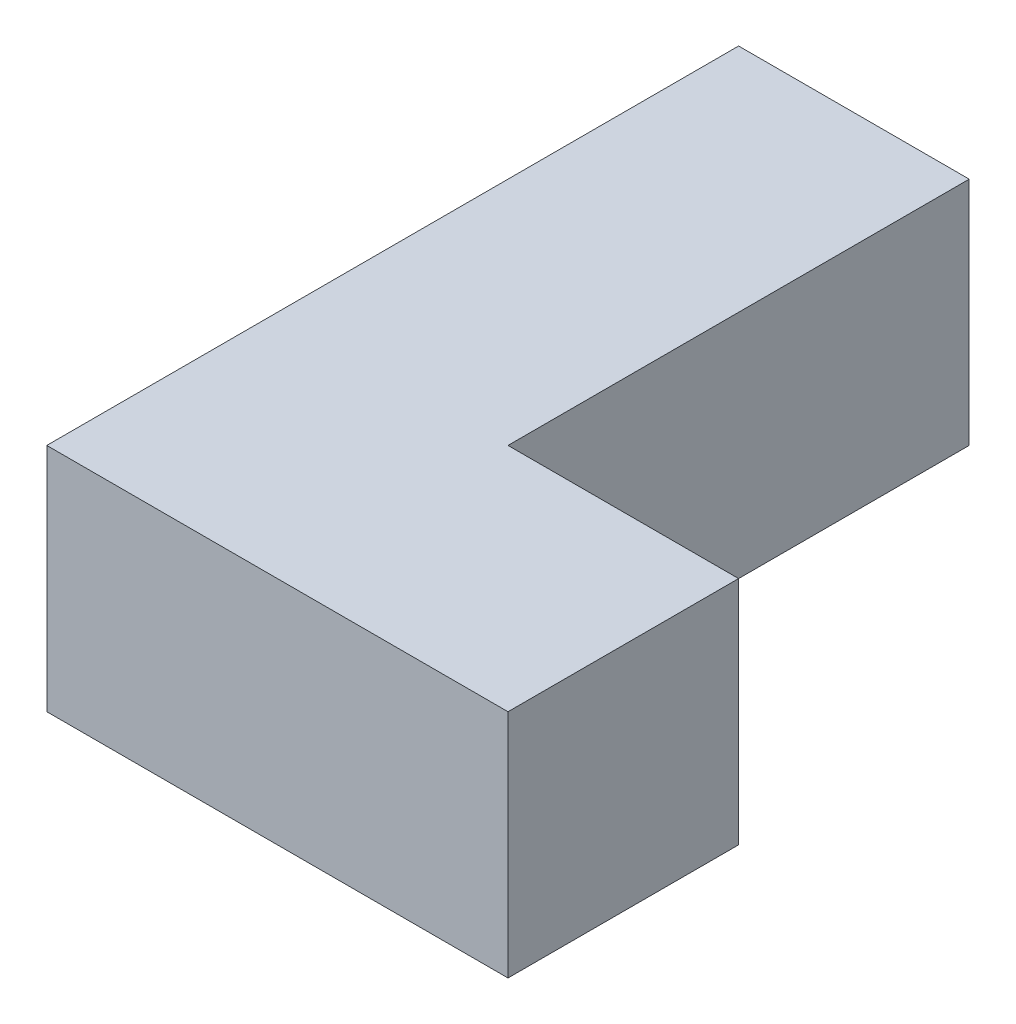
from build123d import *

# Parameters (mm, degrees)
BOSS_EXTRUDE1_DEPTH = 5000


with BuildPart() as part:
    # Sketch1 → Boss-Extrude1 (new body)
    with BuildSketch(Plane(origin=(0, 0, 0), x_dir=(1, 0, 0), z_dir=(0, 1, 0))):
        Polygon((-5000, 7500), (-5000, -7500), (5000, -7500), (5000, -2500), (0, -2500), (0, 7500), align=None)
    extrude(amount=BOSS_EXTRUDE1_DEPTH)


solid = part.part
